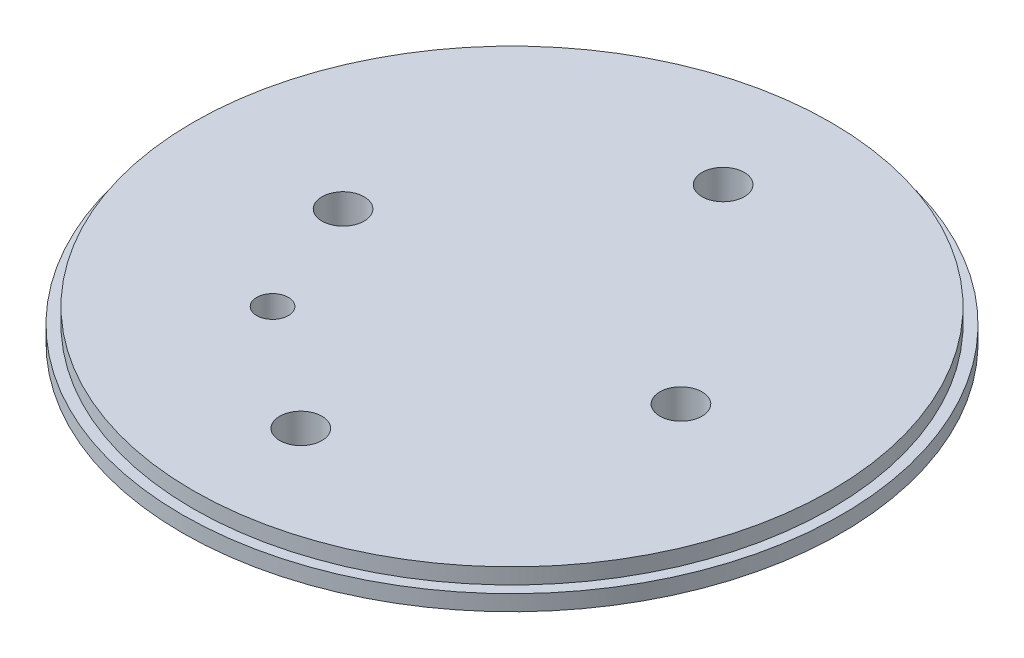
from build123d import *

# Parameters (mm, degrees)
SKETCH1_R           = 49.55
BOSS_EXTRUDE1_DEPTH = 2.36
SKETCH2_R           = 47.95
BOSS_EXTRUDE2_DEPTH = 2.36
SKETCH3_R           = 3.175
SKETCH3_R_2         = 2.38
CUT_EXTRUDE1_DEPTH  = 5.72


with BuildPart() as part:
    # Sketch1 → Boss-Extrude1 (new body)
    with BuildSketch(Plane(origin=(0, 0, 0), x_dir=(1, 0, 0), z_dir=(0, 1, 0))):
        Circle(SKETCH1_R)
    extrude(amount=BOSS_EXTRUDE1_DEPTH)

    # Sketch2 → Boss-Extrude2 (add)
    with BuildSketch(Plane(origin=(0, 2.36, 0), x_dir=(1, 0, 0), z_dir=(0, 1, 0))):
        Circle(SKETCH2_R)
    extrude(amount=BOSS_EXTRUDE2_DEPTH)

    # Sketch3 → Cut-Extrude1 (cut, through all)
    with BuildSketch(Plane.XZ):
        with Locations((25.4, 0)):
            Circle(SKETCH3_R)
        with Locations((-25.4, 0)):
            Circle(SKETCH3_R)
        with Locations((0, 31.75)):
            Circle(SKETCH3_R)
        with Locations((0, -31.75)):
            Circle(SKETCH3_R)
        with Locations((-18, 18)):
            Circle(SKETCH3_R_2)
    extrude(amount=-CUT_EXTRUDE1_DEPTH, mode=Mode.SUBTRACT)


solid = part.part
